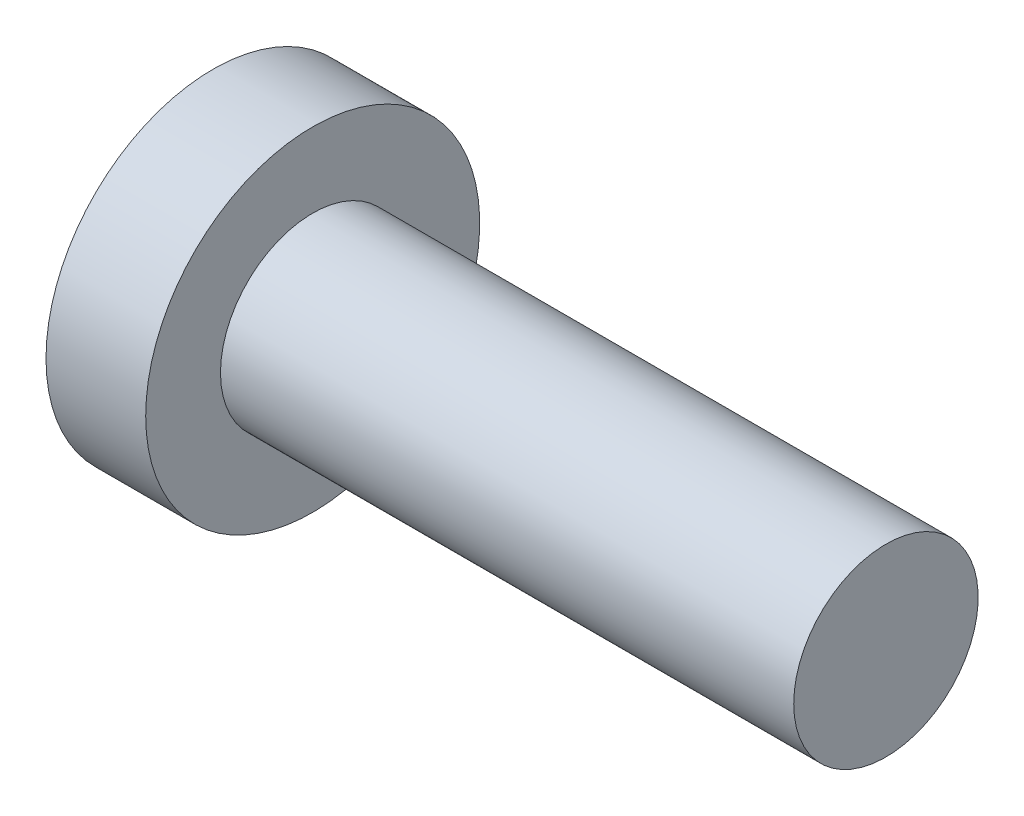
from build123d import *


with BuildPart() as part:
    # Sketch1 → Revolve1 (revolve)
    with BuildSketch(Plane.XY):
        Polygon((-13.5, 0), (-13.5, 6.7), (-9.5, 6.7), (-9.5, 3.7), (13.5, 3.7), (13.5, 0), align=None)
    revolve(axis=Axis((0, 0, 0), (1, 0, 0)))


solid = part.part
